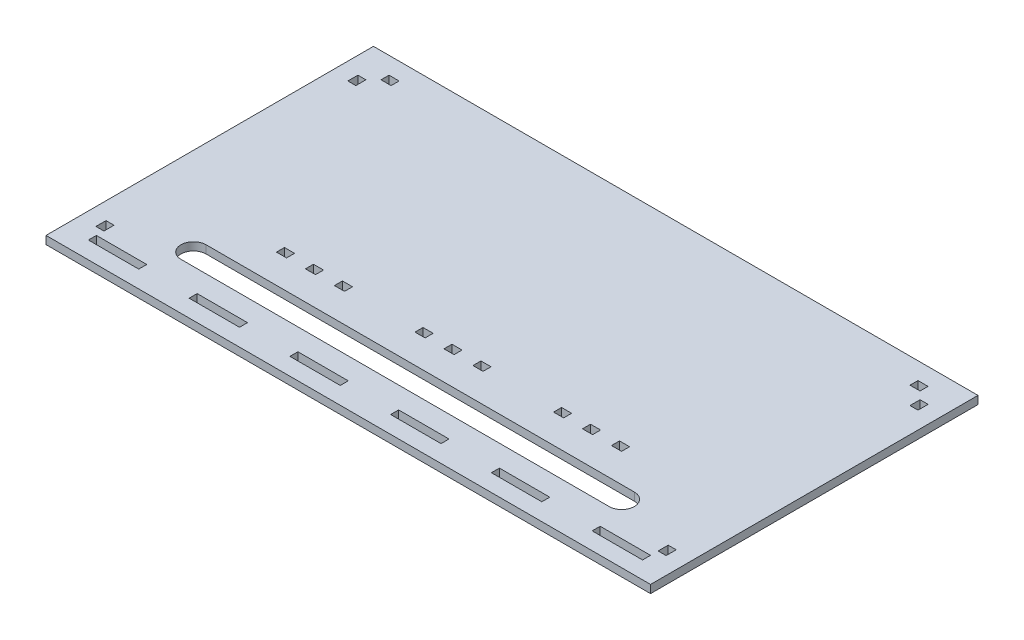
from build123d import *

# Parameters (mm, degrees)
SKETCH1_W           = 240
SKETCH1_H           = 130
SKETCH1_W_2         = 3.175
SKETCH1_H_2         = 4
SKETCH1_W_3         = 4
SKETCH1_H_3         = 3.175
SKETCH1_W_4         = 20
BOSS_EXTRUDE4_DEPTH = 3.175


with BuildPart() as part:
    # Sketch1 → Boss-Extrude4 (new body)
    with BuildSketch(Plane(origin=(0, 0, 0), x_dir=(1, 0, 0), z_dir=(0, 1, 0))):
        Rectangle(SKETCH1_W, SKETCH1_H)
        with Locations((-111.5875, 50)):
            Rectangle(SKETCH1_W_2, SKETCH1_H_2, mode=Mode.SUBTRACT)
        with Locations((-105, 56.5875)):
            Rectangle(SKETCH1_W_3, SKETCH1_H_3, mode=Mode.SUBTRACT)
        with Locations((105, 56.5875)):
            Rectangle(SKETCH1_W_3, SKETCH1_H_3, mode=Mode.SUBTRACT)
        with Locations((111.5875, 50)):
            Rectangle(SKETCH1_W_2, SKETCH1_H_2, mode=Mode.SUBTRACT)
        with Locations((-111.5875, -50)):
            Rectangle(SKETCH1_W_2, SKETCH1_H_2, mode=Mode.SUBTRACT)
        with Locations((-60, -56.5875)):
            Rectangle(SKETCH1_W_4, SKETCH1_H_3, mode=Mode.SUBTRACT)
        with Locations((111.5875, -50)):
            Rectangle(SKETCH1_W_2, SKETCH1_H_2, mode=Mode.SUBTRACT)
        with Locations((-100, -56.5875)):
            Rectangle(SKETCH1_W_4, SKETCH1_H_3, mode=Mode.SUBTRACT)
        with Locations((-20, -56.5875)):
            Rectangle(SKETCH1_W_4, SKETCH1_H_3, mode=Mode.SUBTRACT)
        with Locations((20, -56.5875)):
            Rectangle(SKETCH1_W_4, SKETCH1_H_3, mode=Mode.SUBTRACT)
        with Locations((60, -56.5875)):
            Rectangle(SKETCH1_W_4, SKETCH1_H_3, mode=Mode.SUBTRACT)
        with Locations((100, -56.5875)):
            Rectangle(SKETCH1_W_4, SKETCH1_H_3, mode=Mode.SUBTRACT)
        with Locations((-66.5, -23.4125)):
            Rectangle(SKETCH1_W_3, SKETCH1_H_3, mode=Mode.SUBTRACT)
        with Locations((-55, -23.4125)):
            Rectangle(SKETCH1_W_3, SKETCH1_H_3, mode=Mode.SUBTRACT)
        with Locations((-43.5, -23.4125)):
            Rectangle(SKETCH1_W_3, SKETCH1_H_3, mode=Mode.SUBTRACT)
        with Locations((43.5, -23.4125)):
            Rectangle(SKETCH1_W_3, SKETCH1_H_3, mode=Mode.SUBTRACT)
        with Locations((55, -23.4125)):
            Rectangle(SKETCH1_W_3, SKETCH1_H_3, mode=Mode.SUBTRACT)
        with Locations((66.5, -23.4125)):
            Rectangle(SKETCH1_W_3, SKETCH1_H_3, mode=Mode.SUBTRACT)
        with Locations((-11.5, -23.4125)):
            Rectangle(SKETCH1_W_3, SKETCH1_H_3, mode=Mode.SUBTRACT)
        with Locations((0, -23.4125)):
            Rectangle(SKETCH1_W_3, SKETCH1_H_3, mode=Mode.SUBTRACT)
        with Locations((11.5, -23.4125)):
            Rectangle(SKETCH1_W_3, SKETCH1_H_3, mode=Mode.SUBTRACT)
        with BuildLine():
            Line((-85, -36.438117734), (85, -36.438117734))
            ThreePointArc((85, -36.438117734), (90, -41.438117734), (85, -46.438117734))
            Line((85, -46.438117734), (-85, -46.438117734))
            ThreePointArc((-85, -46.438117734), (-90, -41.438117734), (-85, -36.438117734))
        make_face(mode=Mode.SUBTRACT)
    extrude(amount=BOSS_EXTRUDE4_DEPTH)


solid = part.part
